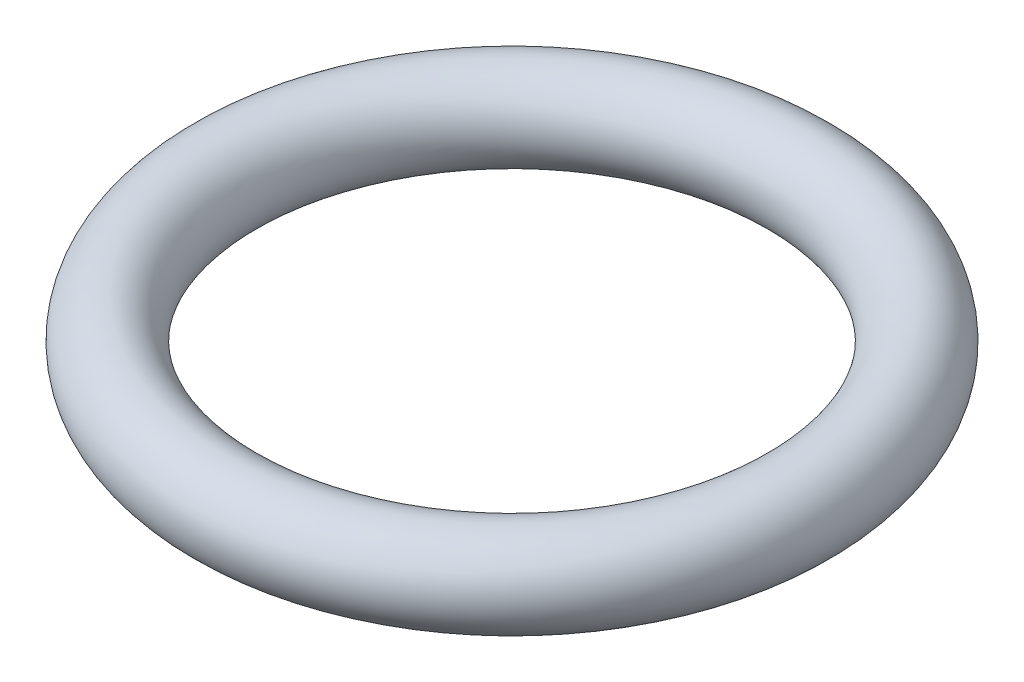
from build123d import *

# Parameters (mm, degrees)
CROQUIS1_R = 1.25


with BuildPart() as part:
    # Croquis1 → Revolución1 (revolve)
    with BuildSketch(Plane.XY):
        with Locations((8.25, 0)):
            Circle(CROQUIS1_R)
    revolve(axis=Axis((0, 7.932692308, 0), (0, -1, 0)))


solid = part.part
